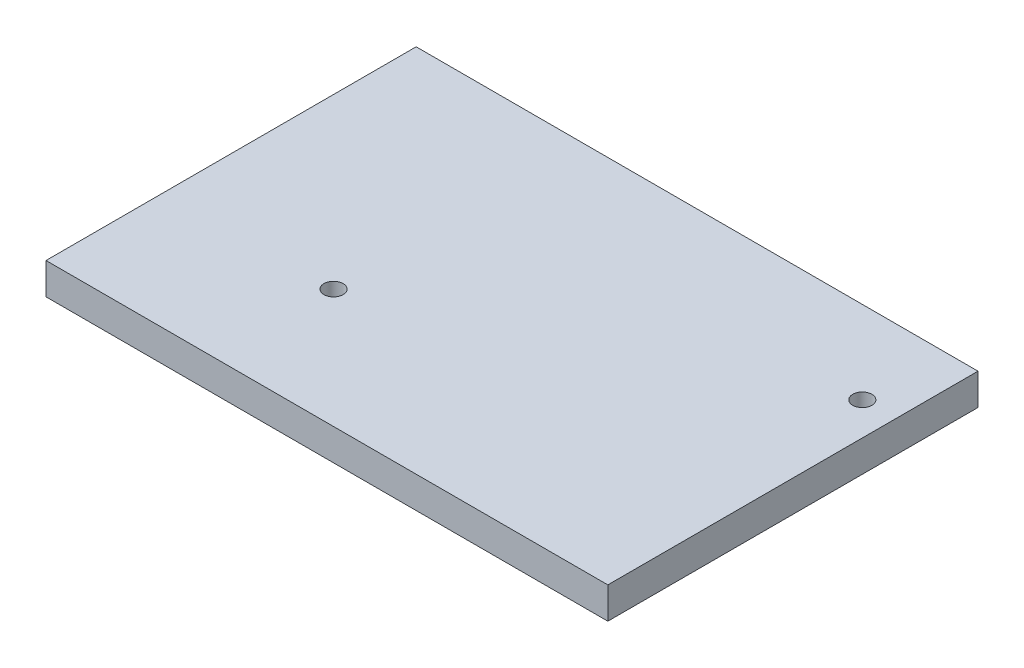
from build123d import *

# Parameters (mm, degrees)
SKETCH1_W                                         = 85
SKETCH1_H                                         = 56
BOSS_EXTRUDE1_DEPTH                               = 4.7625
CSK_FOR_M2_5_FLAT_HEAD_MACHINE_SCREW1_D           = 2.9
CSK_FOR_M2_5_FLAT_HEAD_MACHINE_SCREW1_CSINK_D     = 7.5
CSK_FOR_M2_5_FLAT_HEAD_MACHINE_SCREW1_CSINK_ANGLE = 90


with BuildPart() as part:
    # Sketch1 → Boss-Extrude1 (new body)
    with BuildSketch(Plane(origin=(0, 0, 0), x_dir=(1, 0, 0), z_dir=(0, 1, 0))):
        Rectangle(SKETCH1_W, SKETCH1_H)
    extrude(amount=BOSS_EXTRUDE1_DEPTH)

    # CSK for M2.5 Flat Head Machine Screw1 (through all)
    with Locations(Plane(origin=(-17, 0, 10), x_dir=(0, 0, -1), z_dir=(0, -1, 0))):
        with Locations((0, 0), (25.5, 54.5)):
            CounterSinkHole(CSK_FOR_M2_5_FLAT_HEAD_MACHINE_SCREW1_D / 2, CSK_FOR_M2_5_FLAT_HEAD_MACHINE_SCREW1_CSINK_D / 2, counter_sink_angle=CSK_FOR_M2_5_FLAT_HEAD_MACHINE_SCREW1_CSINK_ANGLE)


solid = part.part
